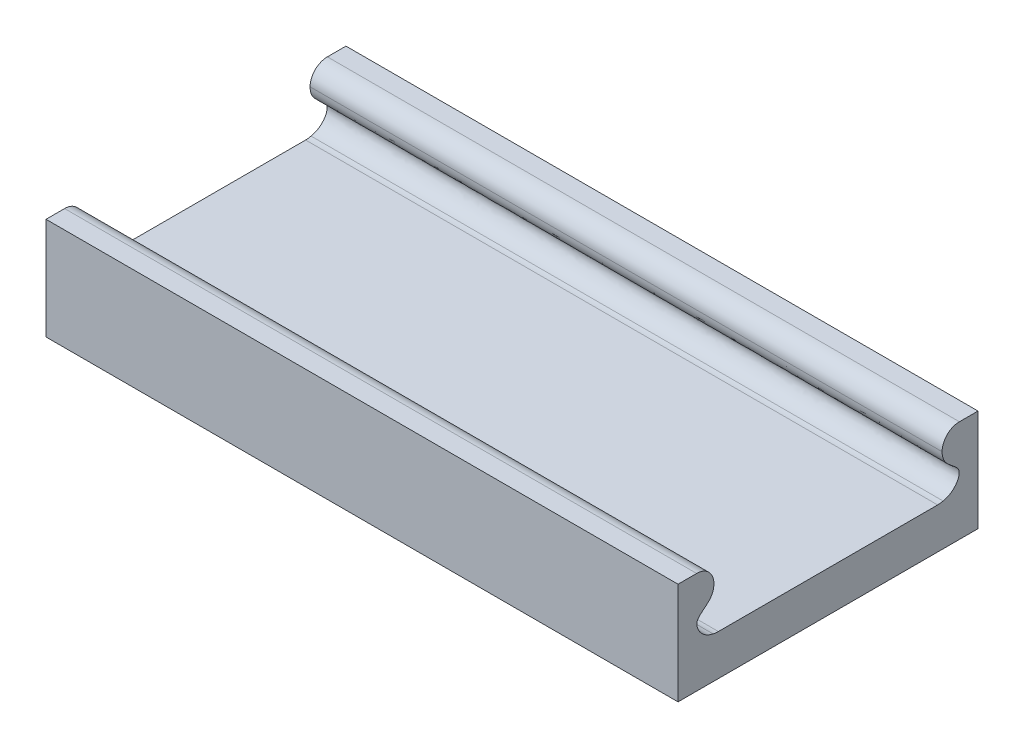
from build123d import *

# Parameters (mm, degrees)
BOSS_EXTRUDE1_DEPTH = 73.824999924
SKETCH2_W           = 5.5
SKETCH2_H           = 11.90625
CUT_EXTRUDE1_DEPTH  = 77


with BuildPart() as part:
    # Sketch1 → Boss-Extrude1 (new body)
    with BuildSketch(Plane(origin=(0, 0, 0), x_dir=(0, 0, -1), z_dir=(1, 0, 0))):
        with BuildLine():
            Line((-16.615833333, 11.90625), (-23.01875, 11.90625))
            Line((-23.01875, 11.90625), (-23.01875, 0))
            Line((-23.01875, 0), (23.01875, 0))
            Line((23.01875, 0), (23.01875, 11.90625))
            Line((23.01875, 11.90625), (16.615833333, 11.90625))
            Line((16.615833333, 11.90625), (15.345833333, 11.90625))
            ThreePointArc((15.345833333, 11.90625), (13.917616741, 11.314663318), (13.326030059, 9.886446726))
            add(Edge.make_bspline(
                [(13.328163425, 9.793638273), (13.326964681, 9.82406182), (13.32624931, 9.854992294), (13.326030059, 9.886446726)],
                knots=[0.989153926, 0.989153926, 0.989153926, 0.989153926, 1, 1, 1, 1], degree=3))
            add(Edge.make_bspline(
                [(13.44097879, 4.843193137), (13.756839485, 4.900565232), (14.289482388, 5.115085376), (14.924667677, 5.682716987), (15.305824568, 6.321722829), (15.357243262, 7.163342963), (14.243691121, 8.123322783), (13.37079951, 8.71155514), (13.328163425, 9.793638273)],
                knots=[0.001929893, 0.001929893, 0.001929893, 0.001929893, 0.146224432, 0.253988964, 0.379668219, 0.474367728, 0.603388454, 0.989153926, 0.989153926, 0.989153926, 0.989153926], degree=3))
            ThreePointArc((13.44097879, 4.843193137), (13.125958752, 4.782754037), (12.805833333, 4.7625))
            Line((12.805833333, 4.7625), (-12.805833333, 4.7625))
            ThreePointArc((-12.805833333, 4.7625), (-13.125958752, 4.782754037), (-13.44097879, 4.843193137))
            add(Edge.make_bspline(
                [(-13.44097879, 4.843193137), (-13.756839485, 4.900565232), (-14.289482388, 5.115085376), (-14.924667677, 5.682716987), (-15.305824568, 6.321722829), (-15.357243262, 7.163342963), (-14.243691121, 8.123322783), (-13.37079951, 8.71155514), (-13.328163425, 9.793638273)],
                knots=[0.001929893, 0.001929893, 0.001929893, 0.001929893, 0.146224432, 0.253988964, 0.379668219, 0.474367728, 0.603388454, 0.989153926, 0.989153926, 0.989153926, 0.989153926], degree=3))
            add(Edge.make_bspline(
                [(-13.328163425, 9.793638273), (-13.326964681, 9.82406182), (-13.32624931, 9.854992294), (-13.326030059, 9.886446726)],
                knots=[0.989153926, 0.989153926, 0.989153926, 0.989153926, 1, 1, 1, 1], degree=3))
            ThreePointArc((-13.326030059, 9.886446726), (-13.917616741, 11.314663318), (-15.345833333, 11.90625))
            Line((-15.345833333, 11.90625), (-16.615833333, 11.90625))
        make_face()
    extrude(amount=BOSS_EXTRUDE1_DEPTH)

    # Sketch2 → Cut-Extrude1 (cut)
    with BuildSketch(Plane(origin=(73.824999924, 0, 0), x_dir=(0, 0, -1), z_dir=(1, 0, 0))):
        with Locations((-20.26875, 5.953125)):
            Rectangle(SKETCH2_W, SKETCH2_H)
        with Locations((20.26875, 5.953125)):
            Rectangle(SKETCH2_W, SKETCH2_H)
    extrude(amount=-CUT_EXTRUDE1_DEPTH, mode=Mode.SUBTRACT)


solid = part.part
